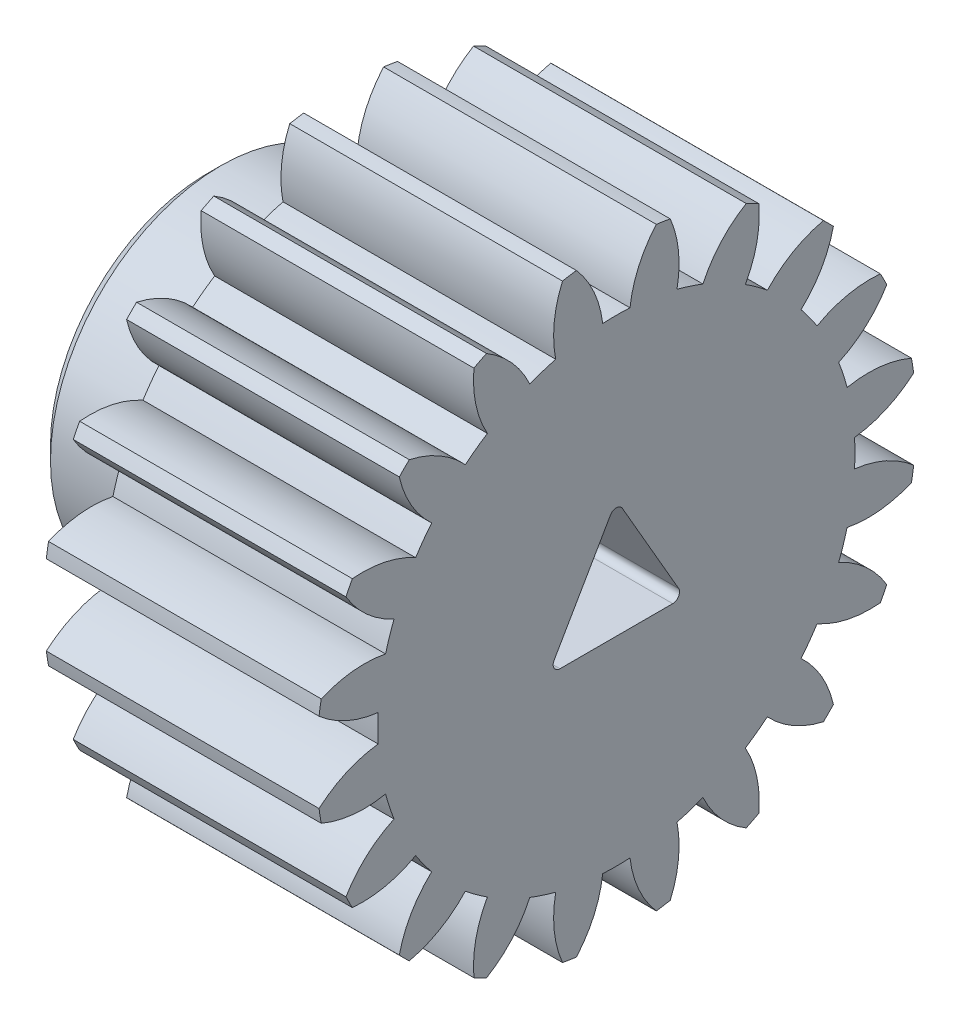
from build123d import *

# Parameters (mm, degrees)
BASPROSKE_W             = 10
BASPROSKE_H             = 11
TOOTHCUT_DEPTH          = 19.493242009
TEETHCUTS_COUNT         = 20
TEETHCUTS_ANGLE         = 342
BORSKE_R                = 0.4
BORE_DEPTH              = 50.0000508
SKETCH1_R               = 6.25
BOSS_EXTRUDE1_DEPTH     = 5
CUT_EXTRUDE1_DEPTH      = 19.376827944
CUT_EXTRUDE1_DEPTH_BACK = 19.376827944
FILLET1_R               = 0.5
CHAMFER1_SIZE           = 0.5
FILLET2_R               = 0.25


with BuildPart() as part:
    # BasProSke → Base-Revolve (revolve)
    with BuildSketch(Plane(origin=(0, 0, 0), x_dir=(1, 0, 0), z_dir=(0, 1, 0)), mode=Mode.PRIVATE) as base_revolve_sk:
        with Locations((5, 5.5)):
            Rectangle(BASPROSKE_W, BASPROSKE_H)
    revolve(base_revolve_sk.sketch.rotate(Axis((-10, 0, 0), (1, 0, 0)), 180), axis=Axis((-10, 0, 0), (1, 0, 0)))

    # TooCutSke → ToothCut (cut, through all)
    with BuildSketch(Plane(origin=(0, 0, 0), x_dir=(0, 0, -1), z_dir=(1, 0, 0))):
        with BuildLine():
            ThreePointArc((0.499924007, 8.734705318), (0, 8.749), (-0.499924007, 8.734705318))
            ThreePointArc((-0.499924007, 8.734705318), (-0.824302243, 9.905497836), (-1.485192705, 10.924909509))
            ThreePointArc((-1.485192705, 10.924909509), (0, 11.0254), (1.485192705, 10.924909509))
            ThreePointArc((1.485192705, 10.924909509), (0.824302243, 9.905497836), (0.499924007, 8.734705318))
        make_face()
    toothcut = extrude(amount=TOOTHCUT_DEPTH, mode=Mode.SUBTRACT)

    # TeethCuts: ToothCut ×20 about axis
    teethcuts_axis = Axis((-10, 0, 0), (1, 0, 0))
    for i in range(1, TEETHCUTS_COUNT):
        add(toothcut.rotate(teethcuts_axis, i * TEETHCUTS_ANGLE / (TEETHCUTS_COUNT - 1)), mode=Mode.SUBTRACT)

    # BorSke → Bore (cut, symmetric)
    with BuildSketch(Plane(origin=(0, 0, 0), x_dir=(0, 0, -1), z_dir=(1, 0, 0))):
        with Locations(Location((0, 0, 0), (0, 0, 180))):
            Circle(BORSKE_R)
    extrude(amount=BORE_DEPTH, both=True, mode=Mode.SUBTRACT)

    # Sketch1 → Boss-Extrude1 (add)
    with BuildSketch(Plane.ZY):
        with Locations(Location((0, 0, 0), (0, 0, 180))):
            Circle(SKETCH1_R)
    extrude(amount=BOSS_EXTRUDE1_DEPTH)

    # Sketch2 → Cut-Extrude1 (cut, two sides)
    with BuildSketch(Plane(origin=(0, 0, 0), x_dir=(0, 0, -1), z_dir=(1, 0, 0))) as cut_extrude1_sk:
        Polygon((-2.5, -1.443375673), (2.5, -1.443375673), (0, 2.886751346), align=None)
    extrude(amount=CUT_EXTRUDE1_DEPTH, mode=Mode.SUBTRACT)
    extrude(cut_extrude1_sk.sketch, amount=-CUT_EXTRUDE1_DEPTH_BACK, mode=Mode.SUBTRACT)

    # Fillet1
    fillet1_edges = [part.edges().sort_by_distance(p)[0] for p in [
        (0, 0, 6.25),
    ]]
    fillet(fillet1_edges, radius=FILLET1_R)

    # Chamfer1
    chamfer1_edges = [part.edges().sort_by_distance(p)[0] for p in [
        (-5, 0, 6.25),
    ]]
    chamfer(chamfer1_edges, length=CHAMFER1_SIZE)

    # Fillet2
    fillet2_edges = [part.edges().sort_by_distance(p)[0] for p in [
        (2.5, -1.443375673, 2.5),
        (2.5, 2.886751346, 0),
        (2.5, -1.443375673, -2.5),
    ]]
    fillet(fillet2_edges, radius=FILLET2_R)


solid = part.part
